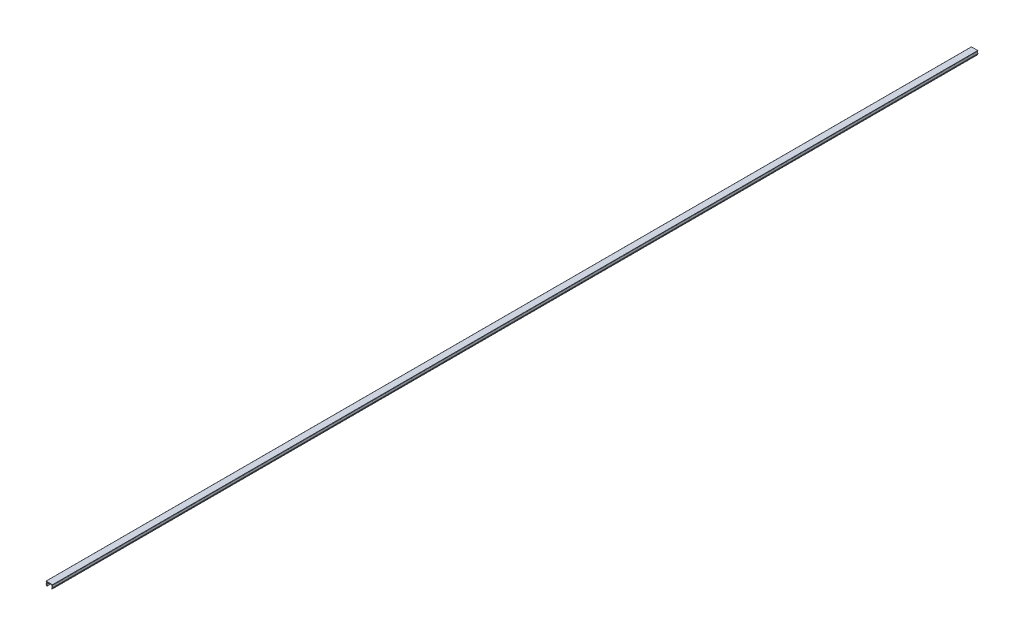
from build123d import *

# Parameters (mm, degrees)
EXTRUDE_1_DEPTH = 1000


with BuildPart() as part:
    # 草图1 → 拉伸1 (new body)
    with BuildSketch(Plane.XY):
        with BuildLine():
            Line((3.719845542, 85.778219074), (3.277947439, 86.992324134))
            ThreePointArc((3.277947439, 86.992324134), (3.2496964, 87.119756335), (3.255389873, 87.250158295))
            Line((3.255389873, 87.250158295), (3.67294288, 89.618219074))
            Line((3.67294288, 89.618219074), (3.17294288, 89.618219074))
            ThreePointArc((3.17294288, 89.618219074), (3.102232202, 89.647508396), (3.07294288, 89.718219074))
            Line((3.07294288, 89.718219074), (3.07294288, 89.918219074))
            ThreePointArc((3.07294288, 89.918219074), (3.131521524, 90.05964043), (3.27294288, 90.118219074))
            Line((3.27294288, 90.118219074), (10.07294288, 90.118219074))
            ThreePointArc((10.07294288, 90.118219074), (10.214364237, 90.05964043), (10.27294288, 89.918219074))
            Line((10.27294288, 89.918219074), (10.27294288, 89.718219074))
            ThreePointArc((10.27294288, 89.718219074), (10.243653558, 89.647508396), (10.17294288, 89.618219074))
            Line((10.17294288, 89.618219074), (9.67294288, 89.618219074))
            Line((9.67294288, 89.618219074), (10.090495888, 87.250158295))
            ThreePointArc((10.090495888, 87.250158295), (10.09618936, 87.119756335), (10.067938321, 86.992324134))
            Line((10.067938321, 86.992324134), (9.626040218, 85.778219074))
            ThreePointArc((9.626040218, 85.778219074), (9.320291197, 85.635645964), (9.177718087, 85.941394985))
            Line((9.177718087, 85.941394985), (9.596882624, 87.093040086))
            ThreePointArc((9.596882624, 87.093040086), (9.602532832, 87.118526526), (9.601394137, 87.144606918))
            Line((9.601394137, 87.144606918), (9.165229574, 89.618219074))
            Line((9.165229574, 89.618219074), (4.180656186, 89.618219074))
            Line((4.180656186, 89.618219074), (3.744491623, 87.144606918))
            ThreePointArc((3.744491623, 87.144606918), (3.743352929, 87.118526526), (3.749003137, 87.093040086))
            Line((3.749003137, 87.093040086), (4.168167674, 85.941394985))
            ThreePointArc((4.168167674, 85.941394985), (4.025594564, 85.635645964), (3.719845542, 85.778219074))
        make_face()
    extrude(amount=EXTRUDE_1_DEPTH)


solid = part.part
